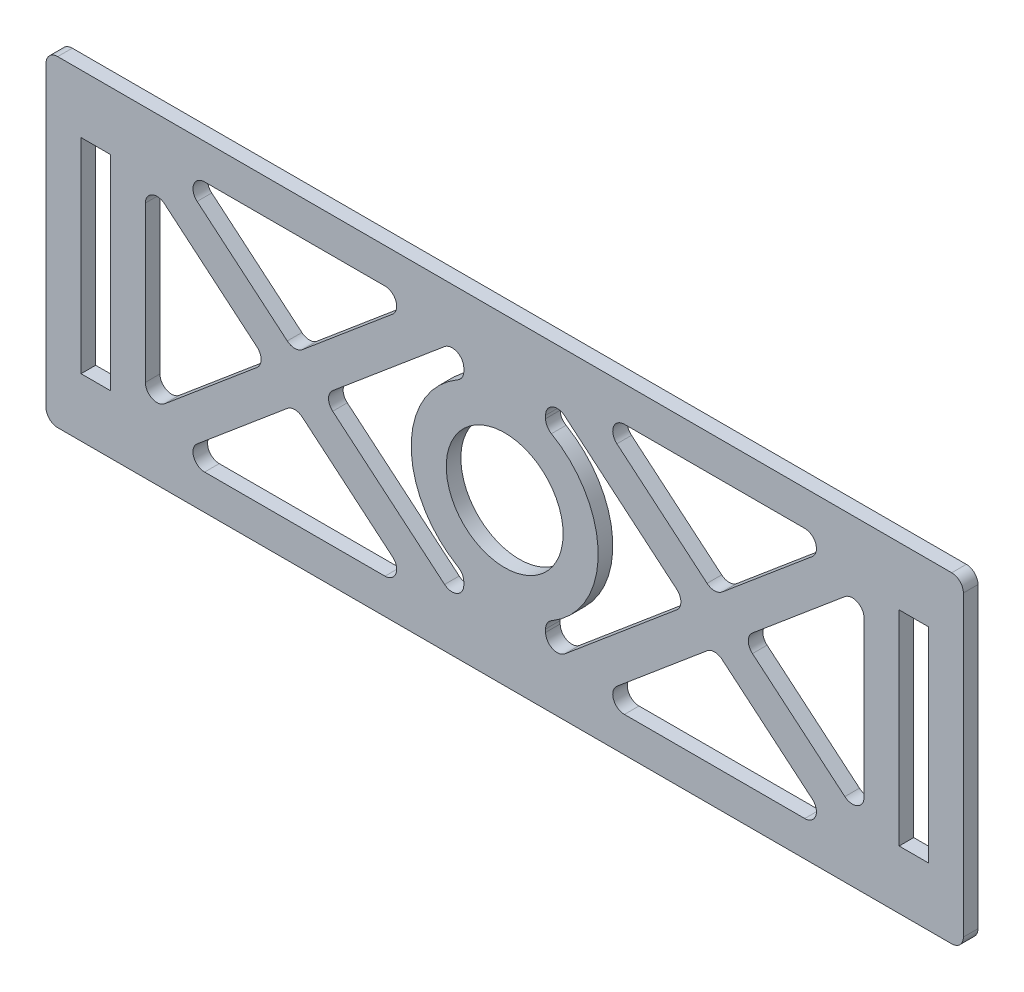
from build123d import *

# Parameters (mm, degrees)
SKETCH1_W           = 199.39
SKETCH1_H           = 69.85
SKETCH1_R           = 12.7
SKETCH1_W_2         = 6.35
SKETCH1_H_2         = 44.45
BOSS_EXTRUDE1_DEPTH = 1.5875
SKETCH1_3_W         = 6.35
SKETCH1_3_H         = 44.45
CUT_EXTRUDE1_DEPTH  = 3.175
FILLET1_R           = 2.54


with BuildPart() as part:
    # Sketch1 → Boss-Extrude1 (new, symmetric)
    with BuildSketch(Plane.XY):
        with Locations((0, -50.8)):
            Rectangle(SKETCH1_W, SKETCH1_H)
        with Locations((0, -50.8)):
            Circle(SKETCH1_R, mode=Mode.SUBTRACT)
        with Locations((88.9, -50.8)):
            Rectangle(SKETCH1_W_2, SKETCH1_H_2, mode=Mode.SUBTRACT)
    extrude(amount=BOSS_EXTRUDE1_DEPTH, both=True)

    # Sketch1_3 → Cut-Extrude1 (cut, symmetric)
    with BuildSketch(Plane.XY):
        with Locations((88.9, -50.8)):
            Rectangle(SKETCH1_3_W, SKETCH1_3_H)
        with BuildLine():
            Line((8.89, -24.907881896), (8.89, -32.527881896))
            ThreePointArc((8.89, -32.527881896), (20.32, -50.8), (8.89, -69.072118104))
            Line((8.89, -69.072118104), (8.89, -76.692118104))
            Line((8.89, -76.692118104), (39.696193404, -50.8))
            Line((39.696193404, -50.8), (8.89, -24.907881896))
        make_face()
        Polygon((72.183420116, -23.495), (19.052126459, -23.495), (45.617773288, -45.823005806), align=None)
        Polygon((72.183420116, -78.105), (45.617773288, -55.776994194), (19.052126459, -78.105), align=None)
        Polygon((78.105, -28.471994194), (51.539353171, -50.8), (78.105, -73.128005806), align=None)
    cut_extrude1 = extrude(amount=CUT_EXTRUDE1_DEPTH, both=True, mode=Mode.SUBTRACT)

    # Mirror1: Cut-Extrude1 across plane
    add(cut_extrude1.mirror(Plane(origin=(0, 0, 0), x_dir=(0, 0, 1), z_dir=(1, 0, 0))), mode=Mode.SUBTRACT)

    # Fillet1
    fillet1_edges = [part.edges().sort_by_distance(p)[0] for p in [
        (51.539353171, -50.8, 0),
        (78.105, -28.471994194, 0),
        (78.105, -73.128005806, 0),
        (39.696193404, -50.8, 0),
        (72.183420116, -78.105, 0),
        (19.052126459, -78.105, 0),
        (45.617773288, -55.776994194, 0),
        (19.052126459, -23.495, 0),
        (72.183420116, -23.495, 0),
        (45.617773288, -45.823005806, 0),
        (99.695, -85.725, 0),
        (99.695, -15.875, 0),
        (-99.695, -85.725, 0),
        (-99.695, -15.875, 0),
        (-78.105, -28.471994194, 0),
        (-51.539353171, -50.8, 0),
        (-78.105, -73.128005806, 0),
        (-39.696193404, -50.8, 0),
        (-72.183420116, -78.105, 0),
        (-45.617773288, -55.776994194, 0),
        (-19.052126459, -78.105, 0),
        (-72.183420116, -23.495, 0),
        (-45.617773288, -45.823005806, 0),
        (-19.052126459, -23.495, 0),
        (-8.89, -32.527881896, 0),
        (-8.89, -76.692118104, 0),
        (-8.89, -24.907881896, 0),
        (-8.89, -69.072118104, 0),
        (8.89, -76.692118104, 0),
        (8.89, -69.072118104, 0),
        (8.89, -32.527881896, 0),
        (8.89, -24.907881896, 0),
    ]]
    fillet(fillet1_edges, radius=FILLET1_R)


solid = part.part
